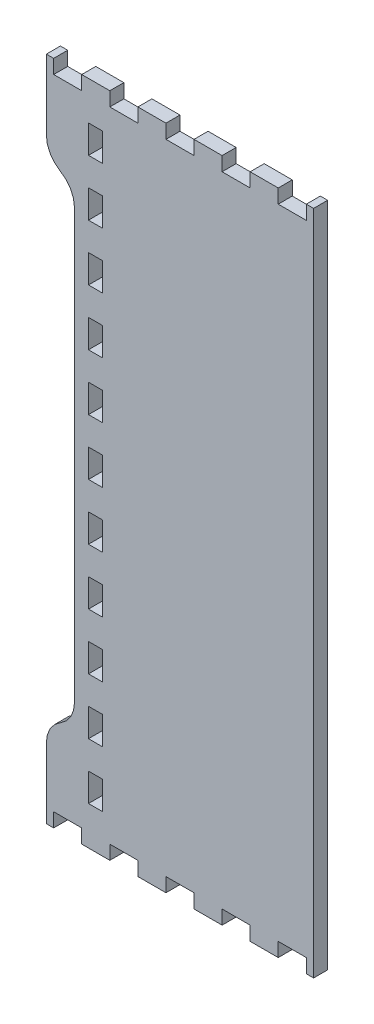
from build123d import *

# Parameters (mm, degrees)
BOSS_EXTRUDE1_DEPTH = 5.715


with BuildPart() as part:
    # Model → Boss-Extrude1 (new body)
    with BuildSketch(Plane.XY):
        Polygon((863.263977742, 22.860238699), (866.236815782, 22.860238699), (866.236815782, 28.575245224), (877.667537494, 28.575245224), (877.667537494, 22.860238699), (889.098259207, 22.860238699), (889.098259207, 28.575245224), (900.528980919, 28.575245224), (900.528980919, 22.860238699), (911.95615932, 22.860238699), (911.95615932, 28.575245224), (923.386881032, 28.575245224), (923.386881032, 22.860238699), (934.817602745, 22.860238699), (934.817602745, 28.575245224), (946.248324457, 28.575245224), (946.248324457, 22.860238699), (957.679046169, 22.860238699), (957.679046169, 28.575245224), (969.10622457, 28.575245224), (969.10622457, 22.860238699), (972.082605921, 22.860238699), (972.082605921, 28.575245224), (972.082605921, 288.575408216), (972.082605921, 294.290414741), (969.10622457, 294.290414741), (969.10622457, 288.575408216), (957.679046169, 288.575408216), (957.679046169, 294.290414741), (946.248324457, 294.290414741), (946.248324457, 288.575408216), (934.817602745, 288.575408216), (934.817602745, 294.290414741), (923.386881032, 294.290414741), (923.386881032, 288.575408216), (911.95615932, 288.575408216), (911.95615932, 294.290414741), (900.528980919, 294.290414741), (900.528980919, 288.575408216), (889.098259207, 288.575408216), (889.098259207, 294.290414741), (877.667537494, 294.290414741), (877.667537494, 288.575408216), (866.236815782, 288.575408216), (866.236815782, 294.290414741), (863.263977742, 294.290414741), (863.263977742, 288.575408216), (863.263977742, 265.715382116), (863.653299053, 262.757291337), (864.794688151, 260.000375591), (866.610192193, 257.633089424), (868.975795287, 255.816433806), (871.344498779, 254.00013252), (873.160445734, 251.633200684), (874.303606488, 248.876284937), (874.694699455, 245.918194159), (874.694699455, 71.232246682), (874.302277747, 68.274290549), (873.160445734, 65.517240157), (871.344498779, 63.150485487), (868.975795287, 61.334361366), (866.610192193, 59.517571103), (864.794688151, 57.150419581), (863.653299053, 54.393369189), (863.263977742, 51.435413056), (863.263977742, 28.575245224), align=None)
        Polygon((880.410060311, 272.875350921), (880.410060311, 278.590357446), (886.121877856, 278.590357446), (886.121877856, 267.160344396), (880.410060311, 267.160344396), align=None, mode=Mode.SUBTRACT)
        Polygon((880.410060311, 250.015324821), (880.410060311, 255.730331346), (886.121877856, 255.730331346), (886.121877856, 244.300318296), (880.410060311, 244.300318296), align=None, mode=Mode.SUBTRACT)
        Polygon((880.410060311, 227.155298721), (880.410060311, 232.870305246), (886.121877856, 232.870305246), (886.121877856, 221.440292196), (880.410060311, 221.440292196), align=None, mode=Mode.SUBTRACT)
        Polygon((880.410060311, 204.295272621), (880.410060311, 210.010279146), (886.121877856, 210.010279146), (886.121877856, 198.580266096), (880.410060311, 198.580266096), align=None, mode=Mode.SUBTRACT)
        Polygon((880.410060311, 181.435246521), (880.410060311, 187.150253046), (886.121877856, 187.150253046), (886.121877856, 175.720239996), (880.410060311, 175.720239996), align=None, mode=Mode.SUBTRACT)
        Polygon((880.410060311, 158.575220421), (880.410060311, 164.290226946), (886.121877856, 164.290226946), (886.121877856, 152.860213896), (880.410060311, 152.860213896), align=None, mode=Mode.SUBTRACT)
        Polygon((880.410060311, 135.71519432), (880.410060311, 141.430200846), (886.121877856, 141.430200846), (886.121877856, 130.000187795), (880.410060311, 130.000187795), align=None, mode=Mode.SUBTRACT)
        Polygon((880.410060311, 112.85516822), (880.410060311, 118.570174745), (886.121877856, 118.570174745), (886.121877856, 107.140161695), (880.410060311, 107.140161695), align=None, mode=Mode.SUBTRACT)
        Polygon((880.410060311, 89.99514212), (880.410060311, 95.710148645), (886.121877856, 95.710148645), (886.121877856, 84.280135595), (880.410060311, 84.280135595), align=None, mode=Mode.SUBTRACT)
        Polygon((880.410060311, 67.13511602), (880.410060311, 72.850122545), (886.121877856, 72.850122545), (886.121877856, 61.420109495), (880.410060311, 61.420109495), align=None, mode=Mode.SUBTRACT)
        Polygon((880.410060311, 44.27508992), (880.410060311, 49.990096445), (886.121877856, 49.990096445), (886.121877856, 38.560083395), (880.410060311, 38.560083395), align=None, mode=Mode.SUBTRACT)
    extrude(amount=BOSS_EXTRUDE1_DEPTH)


solid = part.part
